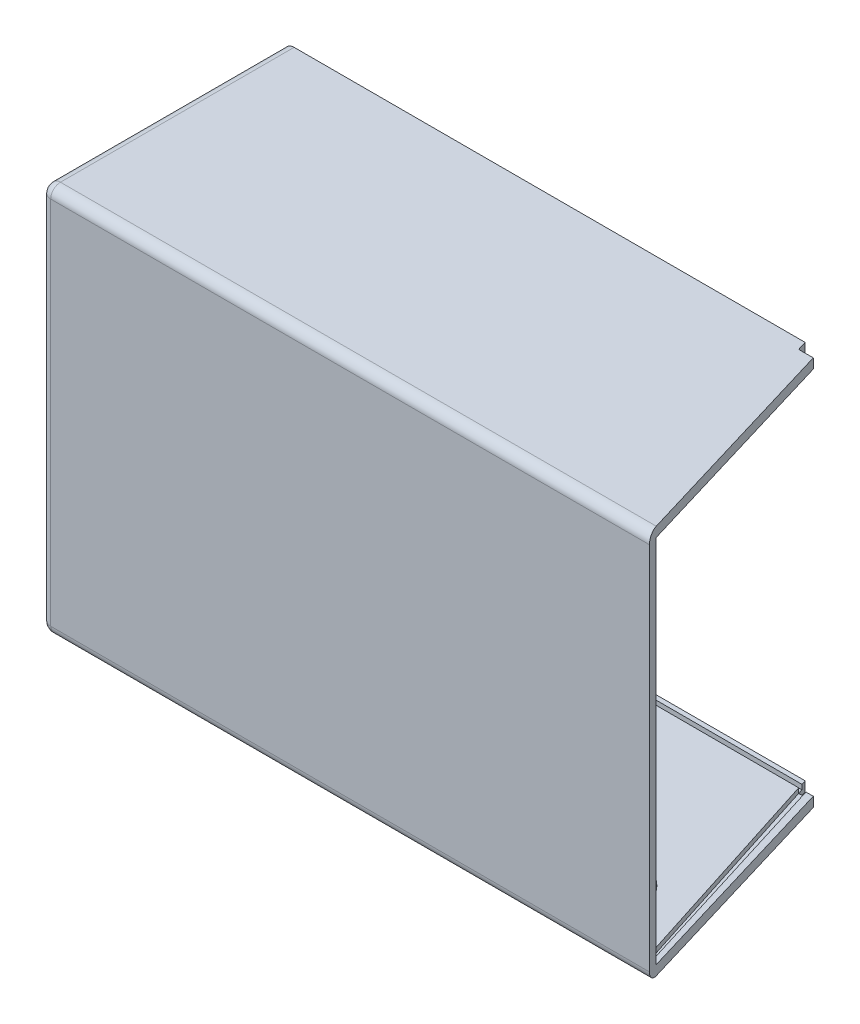
from build123d import *

# Parameters (mm, degrees)
BOSS_EXTRUDE1_DEPTH = 80
SHELL1_T            = -2
CUT_EXTRUDE2_DEPTH  = 92
CUT_EXTRUDE3_DEPTH  = 1
CUT_EXTRUDE4_DEPTH  = 1
SKETCH11_W          = 48.201532545
SKETCH11_H          = 76
CUT_EXTRUDE6_DEPTH  = 2
SKETCH12_W          = 2.088061302
SKETCH12_H          = 76
CUT_EXTRUDE7_DEPTH  = 2
CUT_EXTRUDE9_DEPTH  = 1
CUT_EXTRUDE10_DEPTH = 1
SKETCH16_R          = 3.5
CUT_EXTRUDE11_DEPTH = 2
SKETCH17_R          = 4
SKETCH17_R_2        = 1.5
BOSS_EXTRUDE2_DEPTH = 8
FILLET1_R           = 2


with BuildPart() as part:
    # Sketch2 → Boss-Extrude1 (new body)
    with BuildSketch(Plane(origin=(0, 0, 0), x_dir=(1, 0, 0), z_dir=(0, 1, 0))):
        Polygon((-108.645583258, -36.834647189), (-108.645583258, 13.165352811), (1.354416742, 13.165352811), (16.354416742, -36.834647189), align=None)
    extrude(amount=BOSS_EXTRUDE1_DEPTH)

    # Shell1
    shell1_openings = [part.faces().sort_by_distance(p)[0] for p in [
        (-53.645583258, 40, -13.165352811),
    ]]
    offset(amount=SHELL1_T, openings=shell1_openings, kind=Kind.INTERSECTION)

    # Sketch6 → Cut-Extrude2 (cut)
    with BuildSketch(Plane(origin=(0, 0, 0), x_dir=(-1, 0, 0), z_dir=(0, -1, 0))):
        Polygon((-1.354416742, 13.165352811), (-1.929112513, 11.24970024), (1.070887487, 11.24970024), (1.645583258, 13.165352811), align=None)
    extrude(amount=-CUT_EXTRUDE2_DEPTH, mode=Mode.SUBTRACT)

    # Sketch7 → Cut-Extrude3 (cut)
    with BuildSketch(Plane(origin=(0, 2, 0), x_dir=(1, 0, 0), z_dir=(0, 1, 0))):
        Polygon((-1.070887487, 11.24970024), (-106.645583258, 11.386355729), (-106.645583258, 12.207526526), (-1.358235373, 12.207526526), align=None)
    extrude(amount=-CUT_EXTRUDE3_DEPTH, mode=Mode.SUBTRACT)

    # Sketch9 → Cut-Extrude4 (cut)
    with BuildSketch(Plane(origin=(0, 78, 0), x_dir=(-1, 0, 0), z_dir=(0, -1, 0))):
        with BuildLine():
            Line((1.070887487, 11.24970024), (106.645583258, 11.208974605))
            ThreePointArc((106.645583258, 11.208974605), (106.645716747, 11.901071267), (106.645583258, 12.593167929))
            Line((106.645583258, 12.593167929), (1.358235373, 12.207526526))
            Line((1.358235373, 12.207526526), (1.070887487, 11.24970024))
        make_face()
    extrude(amount=-CUT_EXTRUDE4_DEPTH, mode=Mode.SUBTRACT)

    # Sketch11 → Cut-Extrude6 (cut)
    with BuildSketch(Plane(origin=(4.866075766, 0, -1.45982273), x_dir=(-0.287347886, 0, -0.957826285), z_dir=(0.957826285, 0, -0.287347886))):
        with Locations((-13.879834083, 40)):
            Rectangle(SKETCH11_W, SKETCH11_H)
    extrude(amount=-CUT_EXTRUDE6_DEPTH, mode=Mode.SUBTRACT)

    # Sketch12 → Cut-Extrude7 (cut)
    with BuildSketch(Plane(origin=(0, 0, -11.24970024), x_dir=(-1, 0, 0), z_dir=(0, 0, -1))):
        with Locations((-0.885081862, 40)):
            Rectangle(SKETCH12_W, SKETCH12_H)
    extrude(amount=-CUT_EXTRUDE7_DEPTH, mode=Mode.SUBTRACT)

    # Sketch14 → Cut-Extrude9 (cut)
    with BuildSketch(Plane(origin=(0, 2, 0), x_dir=(1, 0, 0), z_dir=(0, 1, 0))):
        Polygon((-1.070887487, 11.24970024), (0.429112513, 11.24970024), (14.821894685, -35.206342504), (13.8640684, -35.49369039), align=None)
    extrude(amount=-CUT_EXTRUDE9_DEPTH, mode=Mode.SUBTRACT)

    # Sketch15 → Cut-Extrude10 (cut)
    with BuildSketch(Plane(origin=(0, 78, 0), x_dir=(-1, 0, 0), z_dir=(0, -1, 0))):
        Polygon((-13.8640684, -35.49369039), (1.070887487, 11.24970024), (-0.429112513, 11.24970024), (-14.821894685, -35.206342504), align=None)
    extrude(amount=-CUT_EXTRUDE10_DEPTH, mode=Mode.SUBTRACT)

    # Sketch16 → Cut-Extrude11 (cut)
    with BuildSketch(Plane.ZY.offset(108.645583258)):
        with Locations((26.834647189, 10)):
            Circle(SKETCH16_R)
    extrude(amount=-CUT_EXTRUDE11_DEPTH, mode=Mode.SUBTRACT)

    # Sketch17 → Boss-Extrude2 (add)
    with BuildSketch(Plane(origin=(0, 0, 34.834647189), x_dir=(-1, 0, 0), z_dir=(0, 0, -1))):
        with Locations((89.1359316, 72.086299327)):
            Circle(SKETCH17_R)
        with Locations((89.1359316, 72.086299327)):
            Circle(SKETCH17_R_2, mode=Mode.SUBTRACT)
        with Locations((-3.8640684, 72.086299327)):
            Circle(SKETCH17_R)
        with Locations((-3.8640684, 72.086299327)):
            Circle(SKETCH17_R_2, mode=Mode.SUBTRACT)
        with Locations((-3.8640684, 8.086299327)):
            Circle(SKETCH17_R)
        with Locations((-3.8640684, 8.086299327)):
            Circle(SKETCH17_R_2, mode=Mode.SUBTRACT)
        with Locations((89.1359316, 8.086299327)):
            Circle(SKETCH17_R)
        with Locations((89.1359316, 8.086299327)):
            Circle(SKETCH17_R_2, mode=Mode.SUBTRACT)
    extrude(amount=BOSS_EXTRUDE2_DEPTH)

    # Fillet1
    fillet1_edges = [part.edges().sort_by_distance(p)[0] for p in [
        (-46.496042701, 2, 34.834647189),
        (-106.645583258, 40, 34.834647189),
        (-108.645583258, 80, 11.834647189),
        (-46.145583258, 80, 36.834647189),
        (-108.645583258, 0, 11.834647189),
        (-106.645583258, 2, 11.72414573),
        (-46.145583258, 0, 36.834647189),
        (-108.645583258, 40, 36.834647189),
    ]]
    fillet(fillet1_edges, radius=FILLET1_R)


solid = part.part
